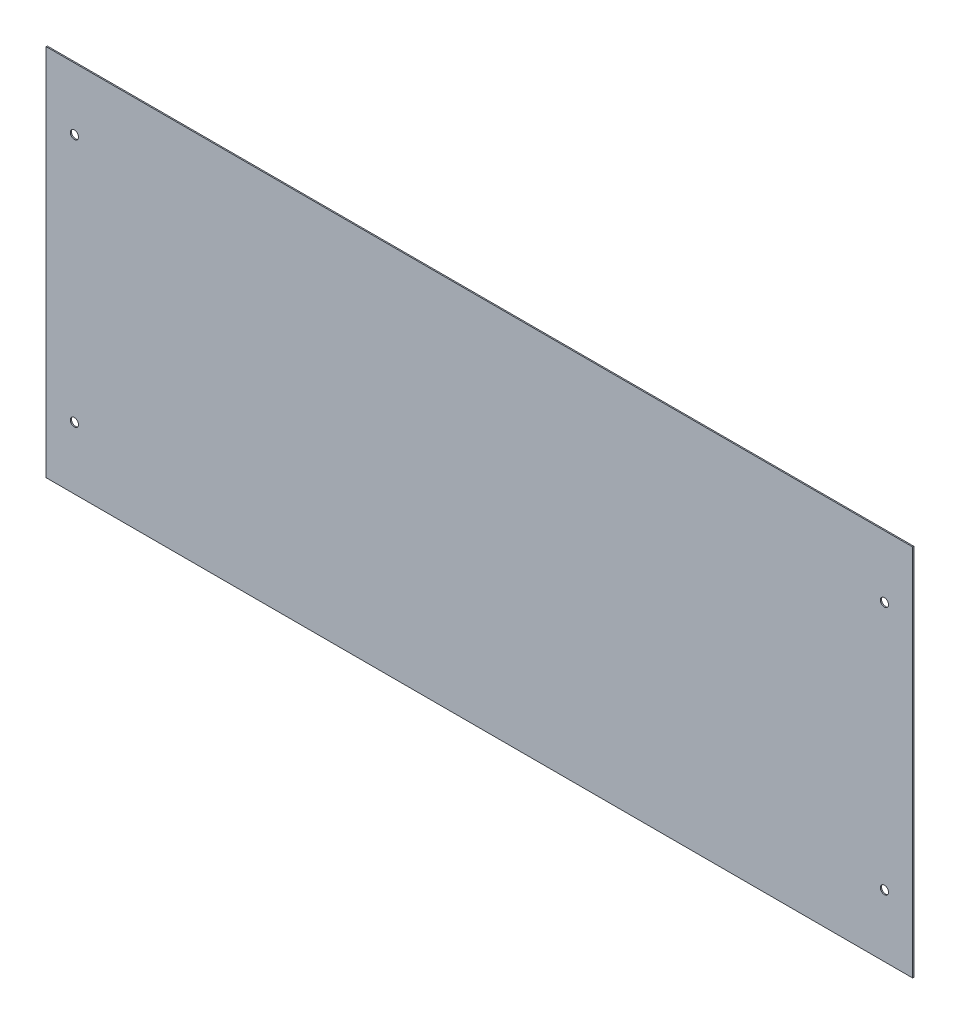
from build123d import *

# Parameters (mm, degrees)
SKETCH1_W           = 738
SKETCH1_H           = 318
SKETCH1_R           = 3.5
BOSS_EXTRUDE1_DEPTH = 1


with BuildPart() as part:
    # Sketch1 → Boss-Extrude1 (new body)
    with BuildSketch(Plane.XY):
        with Locations((369, 159)):
            Rectangle(SKETCH1_W, SKETCH1_H)
        with Locations((24, 265.06)):
            Circle(SKETCH1_R, mode=Mode.SUBTRACT)
        with Locations((714, 265.06)):
            Circle(SKETCH1_R, mode=Mode.SUBTRACT)
        with Locations((714, 52.94)):
            Circle(SKETCH1_R, mode=Mode.SUBTRACT)
        with Locations((24, 52.94)):
            Circle(SKETCH1_R, mode=Mode.SUBTRACT)
    extrude(amount=BOSS_EXTRUDE1_DEPTH)


solid = part.part
